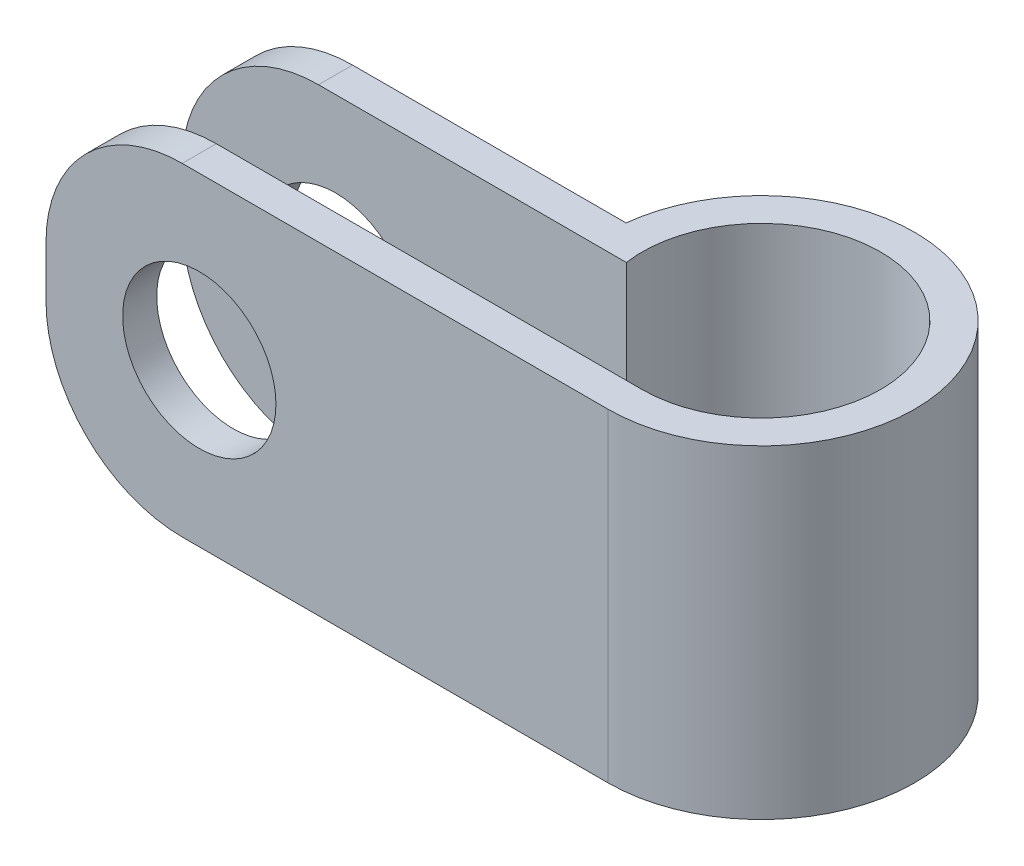
from build123d import *

# Parameters (mm, degrees)
BOSS_EXTRUDE1_DEPTH = 4.75
SKETCH2_R           = 2.25
CUT_EXTRUDE1_DEPTH  = 10
FILLET1_R           = 4


with BuildPart() as part:
    # Sketch1 → Boss-Extrude1 (new body, symmetric)
    with BuildSketch(Plane(origin=(0, 0, 0), x_dir=(1, 0, 0), z_dir=(0, 1, 0))):
        with BuildLine():
            Line((0, -3.5), (-16.5, -3.5))
            Line((-16.5, -3.5), (-16.5, -4.5))
            Line((-16.5, -4.5), (0, -4.5))
            ThreePointArc((0, -4.5), (3.354101966, 3), (-4.472135955, 0.5))
            Line((-4.472135955, 0.5), (-16.5, 0.5))
            Line((-16.5, 0.5), (-16.5, -0.5))
            Line((-16.5, -0.5), (-3.464101615, -0.5))
            ThreePointArc((-3.464101615, -0.5), (2.291287847, 2.645751311), (0, -3.5))
        make_face()
    extrude(amount=BOSS_EXTRUDE1_DEPTH, both=True)

    # Sketch2 → Cut-Extrude1 (cut, through all)
    with BuildSketch(Plane.XY.offset(4.5)):
        with Locations((-12, 0)):
            Circle(SKETCH2_R)
    extrude(amount=-CUT_EXTRUDE1_DEPTH, mode=Mode.SUBTRACT)

    # Fillet1
    fillet1_edges = [part.edges().sort_by_distance(p)[0] for p in [
        (-16.5, 4.75, 4),
        (-16.5, 4.75, 0),
        (-16.5, -4.75, 0),
        (-16.5, -4.75, 4),
    ]]
    fillet(fillet1_edges, radius=FILLET1_R)


solid = part.part
